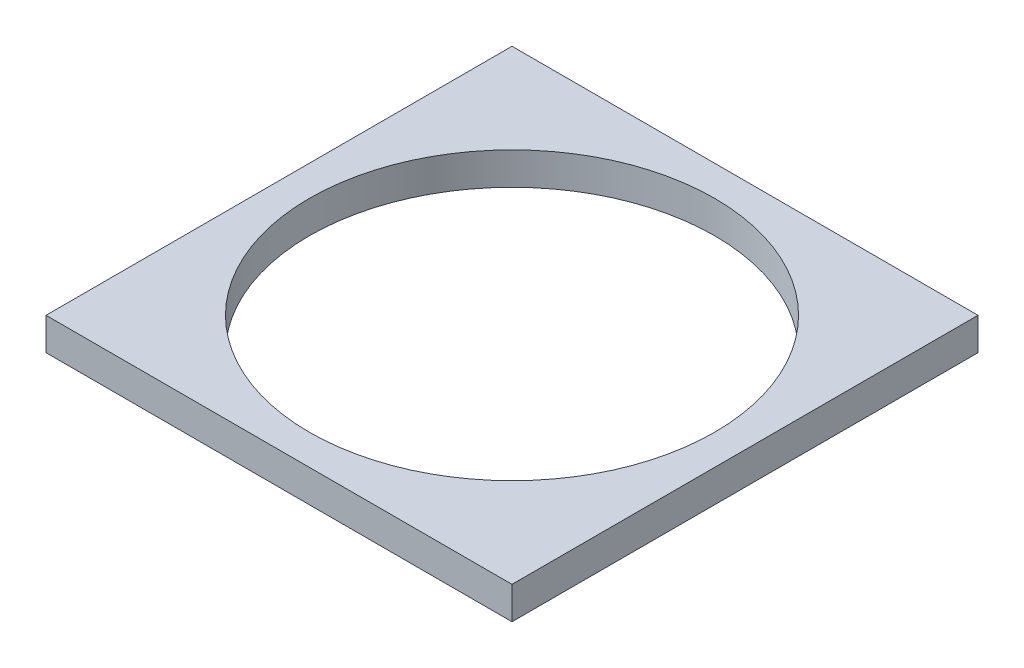
from build123d import *

# Parameters (mm, degrees)
SKETCH1_W           = 11.5
SKETCH1_H           = 11.5
SKETCH1_R           = 5
BOSS_EXTRUDE1_DEPTH = 0.8


with BuildPart() as part:
    # Sketch1 → Boss-Extrude1 (new body)
    with BuildSketch(Plane(origin=(0, 0, 0), x_dir=(1, 0, 0), z_dir=(0, 1, 0))):
        with Locations((-3.194444444, 3.057539683)):
            Rectangle(SKETCH1_W, SKETCH1_H)
        with Locations((-3.194444444, 3.057539683)):
            Circle(SKETCH1_R, mode=Mode.SUBTRACT)
    extrude(amount=BOSS_EXTRUDE1_DEPTH)


solid = part.part
